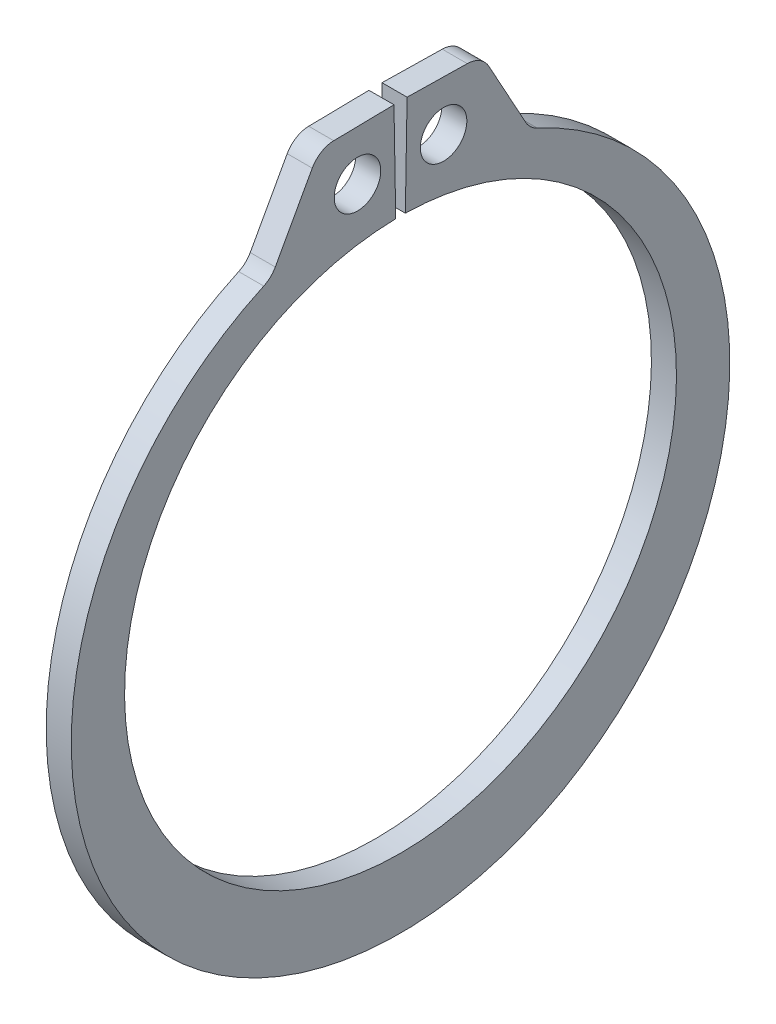
from build123d import *

# Parameters (mm, degrees)
SKETCH1_R      = 0.9906
EXTRUDE1_DEPTH = 0.5334
FILLET1_R      = 1.0668


with BuildPart() as part:
    # Sketch1 → Extrude1 (new, symmetric)
    with BuildSketch(Plane(origin=(0, 0, 0), x_dir=(0, 0, -1), z_dir=(1, 0, 0))):
        with BuildLine():
            Line((-0.205022145, 11.745710799), (-0.279051762, 15.986864752))
            Line((-0.279051762, 15.986864752), (-3.459917227, 15.931342539))
            Line((-3.459917227, 15.931342539), (-5.505255869, 12.215234753))
            ThreePointArc((-5.505255869, 12.215234753), (0, -14.6939), (5.505255869, 12.215234753))
            Line((5.505255869, 12.215234753), (3.459917227, 15.931342539))
            Line((3.459917227, 15.931342539), (0.279051762, 15.986864752))
            Line((0.279051762, 15.986864752), (0.205022145, 11.745710799))
            ThreePointArc((0.205022145, 11.745710799), (0, -11.7475), (-0.205022145, 11.745710799))
        make_face()
        with Locations((-1.832469686, 13.838526669)):
            Circle(SKETCH1_R, mode=Mode.SUBTRACT)
        with Locations((1.832469686, 13.838526669)):
            Circle(SKETCH1_R, mode=Mode.SUBTRACT)
    extrude(amount=EXTRUDE1_DEPTH, both=True)

    # Fillet1
    fillet1_edges = [part.edges().sort_by_distance(p)[0] for p in [
        (0, 15.931342539, -3.459917227),
        (0, 12.215234753, -5.505255869),
        (0, 12.215234753, 5.505255869),
        (0, 15.931342539, 3.459917227),
    ]]
    fillet(fillet1_edges, radius=FILLET1_R)


solid = part.part
